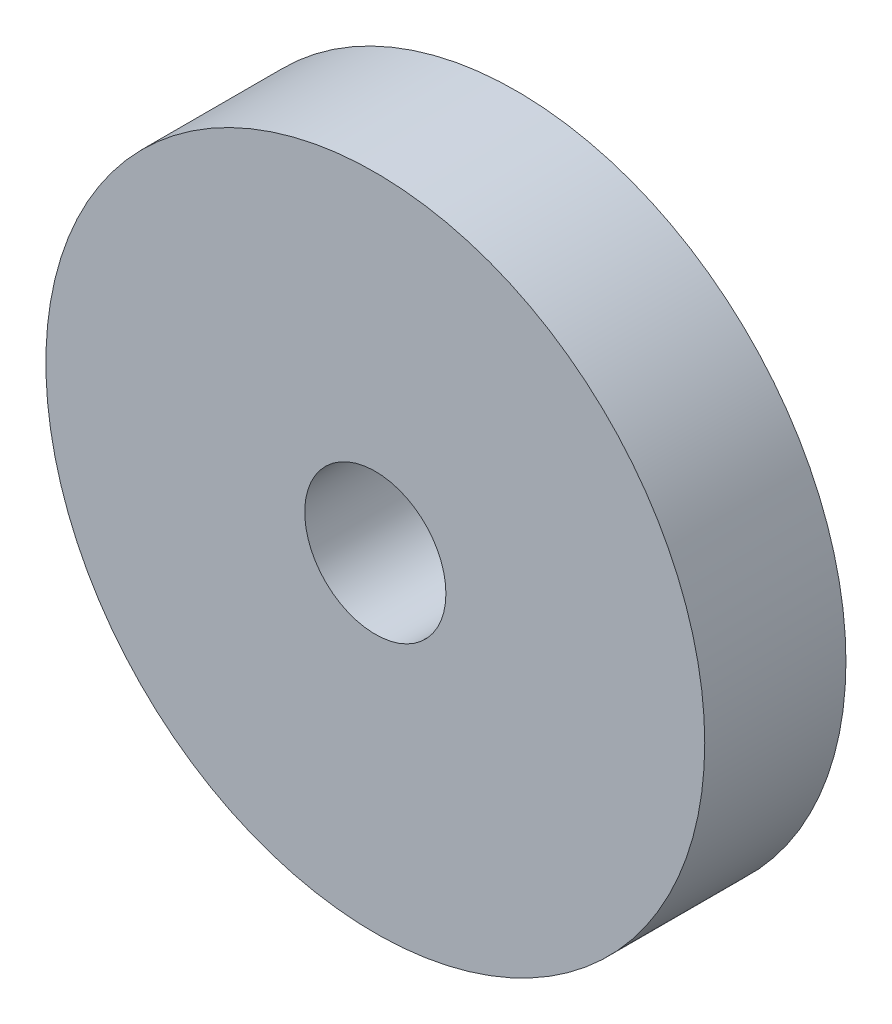
from build123d import *

# Parameters (mm, degrees)
SKETCH1_R           = 7
BOSS_EXTRUDE1_DEPTH = 3
SKETCH2_R           = 1.5
CUT_EXTRUDE1_DEPTH  = 3


with BuildPart() as part:
    # Sketch1 → Boss-Extrude1 (new body)
    with BuildSketch(Plane.XY):
        Circle(SKETCH1_R)
    extrude(amount=BOSS_EXTRUDE1_DEPTH)

    # Sketch2 → Cut-Extrude1 (cut)
    with BuildSketch(Plane.XY.offset(3)):
        Circle(SKETCH2_R)
    extrude(amount=-CUT_EXTRUDE1_DEPTH, mode=Mode.SUBTRACT)


solid = part.part
